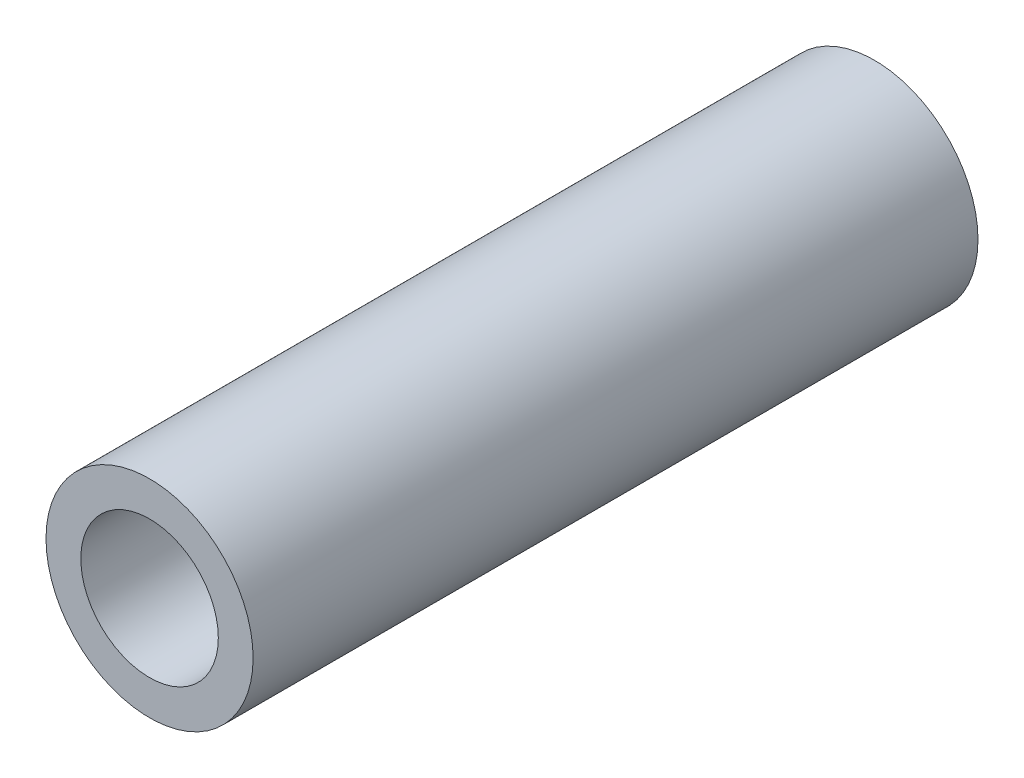
from build123d import *

# Parameters (mm, degrees)
SKETCH1_R      = 3.175
SKETCH1_R_2    = 2.1082
EXTRUDE1_DEPTH = 11.1125


with BuildPart() as part:
    # Sketch1 → Extrude1 (new body, symmetric)
    with BuildSketch(Plane.XY):
        Circle(SKETCH1_R)
        Circle(SKETCH1_R_2, mode=Mode.SUBTRACT)
    extrude(amount=EXTRUDE1_DEPTH, both=True)


solid = part.part
